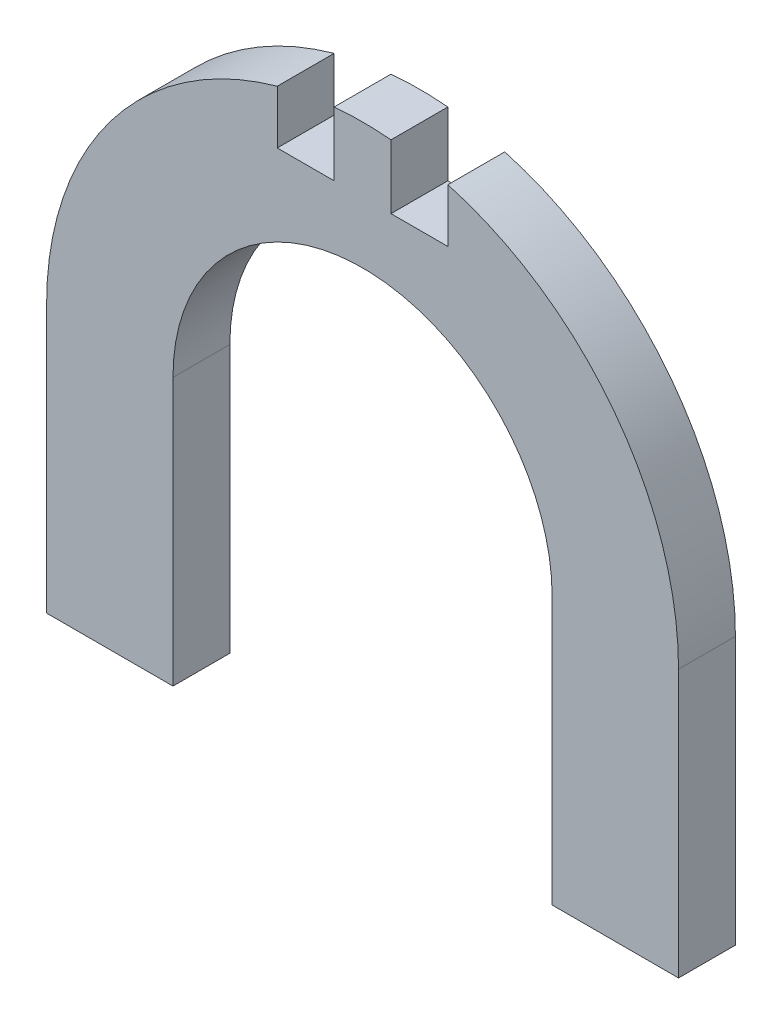
from build123d import *

# Parameters (mm, degrees)
BOSS_EXTRUDE1_DEPTH = 18
SKETCH2_W           = 18
SKETCH2_H           = 46.670060525
CUT_EXTRUDE1_DEPTH  = 19
SKETCH3_W           = 40
SKETCH3_H           = 18
BOSS_EXTRUDE2_DEPTH = 44


with BuildPart() as part:
    # Sketch1 → Boss-Extrude1 (new body)
    with BuildSketch(Plane.XY):
        with BuildLine():
            Line((60, 60), (60, 100.646547639))
            ThreePointArc((60, 100.646547639), (0, 160.646547639), (-60, 100.646547639))
            Line((-60, 100.646547639), (-60, 60))
            Line((-60, 60), (-100, 60))
            Line((-100, 60), (-100, 100.646547639))
            ThreePointArc((-100, 100.646547639), (0, 200.646547639), (100, 100.646547639))
            Line((100, 100.646547639), (100, 60))
            Line((100, 60), (60, 60))
        make_face()
    extrude(amount=BOSS_EXTRUDE1_DEPTH)

    # Sketch2 → Cut-Extrude1 (cut, through all)
    with BuildSketch(Plane.XY.offset(18)):
        with Locations((18, 203.335030263)):
            Rectangle(SKETCH2_W, SKETCH2_H)
        with Locations((-18, 203.335030263)):
            Rectangle(SKETCH2_W, SKETCH2_H)
    extrude(amount=-CUT_EXTRUDE1_DEPTH, mode=Mode.SUBTRACT)

    # Sketch3 → Boss-Extrude2 (add)
    with BuildSketch(Plane.XZ.offset(-60)):
        with Locations((-80, 9)):
            Rectangle(SKETCH3_W, SKETCH3_H)
        with Locations((80, 9)):
            Rectangle(SKETCH3_W, SKETCH3_H)
    extrude(amount=BOSS_EXTRUDE2_DEPTH)


solid = part.part
